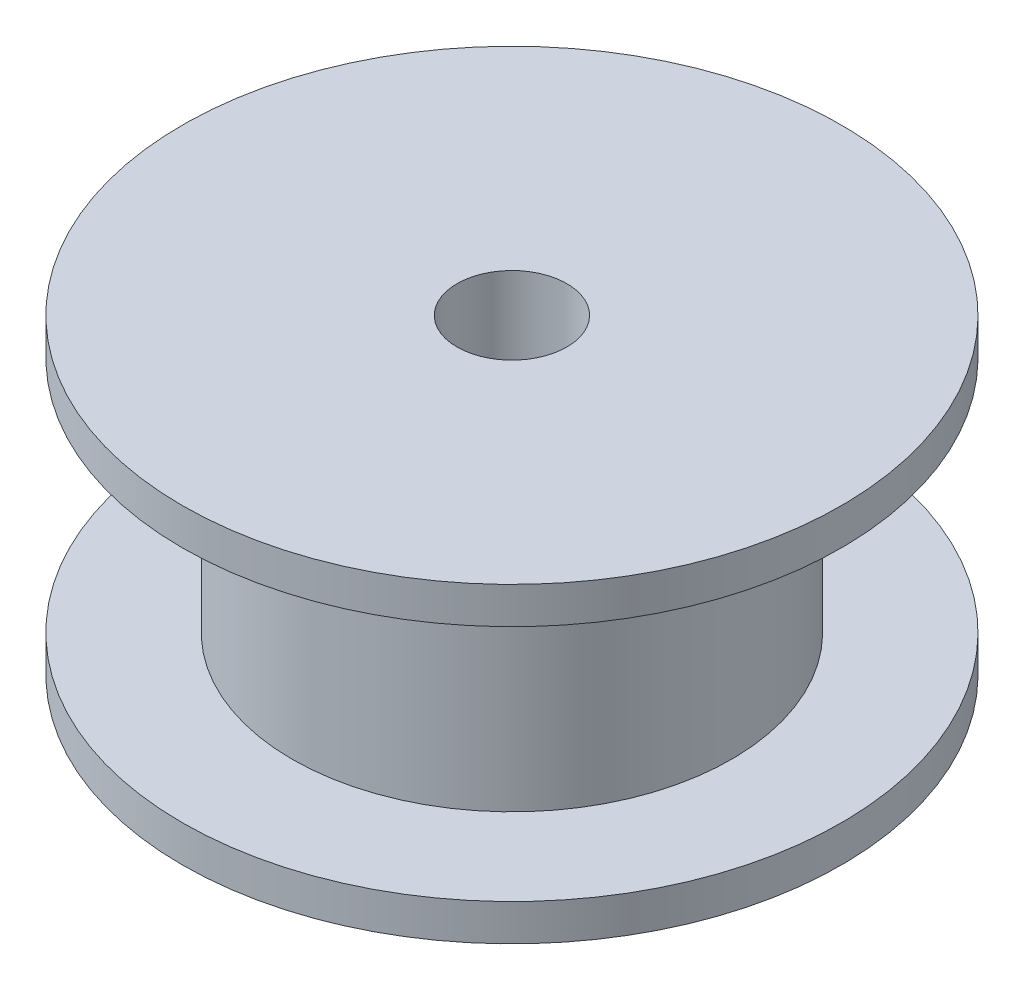
from build123d import *

# Parameters (mm, degrees)
SKETCH_1_R          = 9
EXTRUDE_1_DEPTH     = 1
SKETCH_2_R          = 6
EXTRUDE_2_DEPTH     = 6.5
SKETCH_3_R          = 9
EXTRUDE_3_DEPTH     = 1
SKETCH_4_R          = 1.5
CUT_EXTRUDE_1_DEPTH = 9.5


with BuildPart() as part:
    # 草图1 → 凸台-拉伸1 (new body)
    with BuildSketch(Plane(origin=(0, 0, 0), x_dir=(1, 0, 0), z_dir=(0, 1, 0))):
        Circle(SKETCH_1_R)
    extrude(amount=EXTRUDE_1_DEPTH)

    # 草图2 → 凸台-拉伸2 (add)
    with BuildSketch(Plane(origin=(0, 1, 0), x_dir=(1, 0, 0), z_dir=(0, 1, 0))):
        Circle(SKETCH_2_R)
    extrude(amount=EXTRUDE_2_DEPTH)

    # 草图3 → 凸台-拉伸3 (add)
    with BuildSketch(Plane(origin=(0, 7.5, 0), x_dir=(1, 0, 0), z_dir=(0, 1, 0))):
        Circle(SKETCH_3_R)
    extrude(amount=EXTRUDE_3_DEPTH)

    # 草图4 → 切除-拉伸1 (cut, through all)
    with BuildSketch(Plane(origin=(0, 8.5, 0), x_dir=(1, 0, 0), z_dir=(0, 1, 0))):
        Circle(SKETCH_4_R)
    extrude(amount=-CUT_EXTRUDE_1_DEPTH, mode=Mode.SUBTRACT)


solid = part.part
